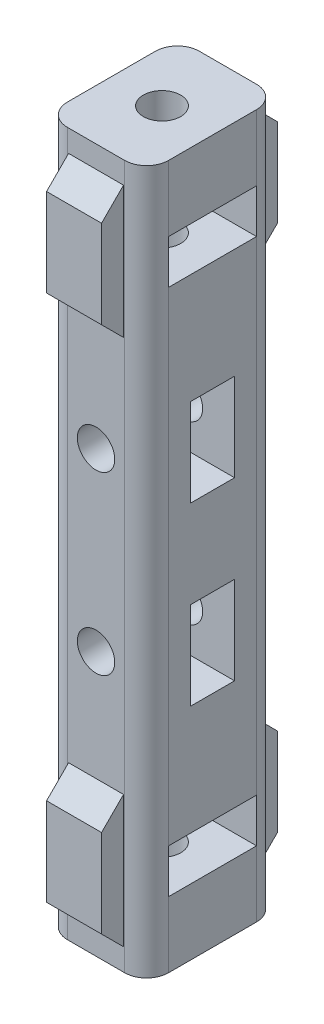
from build123d import *

# Parameters (mm, degrees)
SKETCH1_W           = 4.6
SKETCH1_H           = 6
SKETCH1_R           = 0.85
EXTRUDE1_DEPTH      = 32
EXTRUDE2_DEPTH      = 1.25
SKETCH3_R           = 0.85
EXTRUDE4_DEPTH      = 8
FILLET2_R           = 1
SKETCH_W            = 4
SKETCH_H            = 2
EXTRUDE5_DEPTH      = 4.6
EXTRUDE5_DEPTH_BACK = 4.6
SKETCH4_W           = 2
SKETCH4_H           = 4
EXTRUDE6_DEPTH      = 3.3
EXTRUDE6_DEPTH_BACK = 3.3


with BuildPart() as part:
    # Sketch1 → Extrude1 (new body)
    with BuildSketch(Plane(origin=(0, 0, 0), x_dir=(1, 0, 0), z_dir=(0, 1, 0))):
        Rectangle(SKETCH1_W, SKETCH1_H)
        with Locations(Location((0, 0, 0), (0, 0, 270))):  # turned: the seam where the file's is
            Circle(SKETCH1_R, mode=Mode.SUBTRACT)
    extrude(amount=EXTRUDE1_DEPTH)

    # Sketch2 → Extrude2 (add, symmetric)
    with BuildSketch(Plane(origin=(0, 0, 0), x_dir=(0, 0, -1), z_dir=(1, 0, 0))):
        Polygon((-3, 25), (-3, 31), (-4, 30), (-4, 26), align=None)
        Polygon((3, 31), (3, 25), (4, 26), (4, 30), align=None)
        Polygon((-4, 2), (-3, 1), (-3, 7), (-4, 6), align=None)
        Polygon((4, 6), (3, 7), (3, 1), (4, 2), align=None)
    extrude(amount=EXTRUDE2_DEPTH, both=True)

    # Sketch3 → Extrude4 (cut, through all)
    with BuildSketch(Plane.XY.offset(3)):
        with Locations((0, 20)):
            Circle(SKETCH3_R)
        with Locations((0, 12)):
            Circle(SKETCH3_R)
    extrude(amount=-EXTRUDE4_DEPTH, mode=Mode.SUBTRACT)

    # Fillet2
    fillet2_edges = [part.edges().sort_by_distance(p)[0] for p in [
        (-2.3, 16, -3),
        (2.3, 16, -3),
        (2.3, 16, 3),
        (-2.3, 16, 3),
    ]]
    fillet(fillet2_edges, radius=FILLET2_R)

    # Sketch → Extrude5 (cut, two sides)
    with BuildSketch(Plane(origin=(0, 0, 0), x_dir=(0, 0, -1), z_dir=(1, 0, 0))) as extrude5_sk:
        with Locations((0, 28)):
            Rectangle(SKETCH_W, SKETCH_H)
        with Locations((0, 4)):
            Rectangle(SKETCH_W, SKETCH_H)
    extrude(amount=EXTRUDE5_DEPTH, mode=Mode.SUBTRACT)
    extrude(extrude5_sk.sketch, amount=-EXTRUDE5_DEPTH_BACK, mode=Mode.SUBTRACT)

    # Sketch4 → Extrude6 (cut, two sides)
    with BuildSketch(Plane(origin=(0, 0, 0), x_dir=(0, 0, -1), z_dir=(1, 0, 0))) as extrude6_sk:
        with Locations((0, 20)):
            Rectangle(SKETCH4_W, SKETCH4_H)
        with Locations((0, 12)):
            Rectangle(SKETCH4_W, SKETCH4_H)
    extrude(amount=EXTRUDE6_DEPTH, mode=Mode.SUBTRACT)
    extrude(extrude6_sk.sketch, amount=-EXTRUDE6_DEPTH_BACK, mode=Mode.SUBTRACT)


solid = part.part
